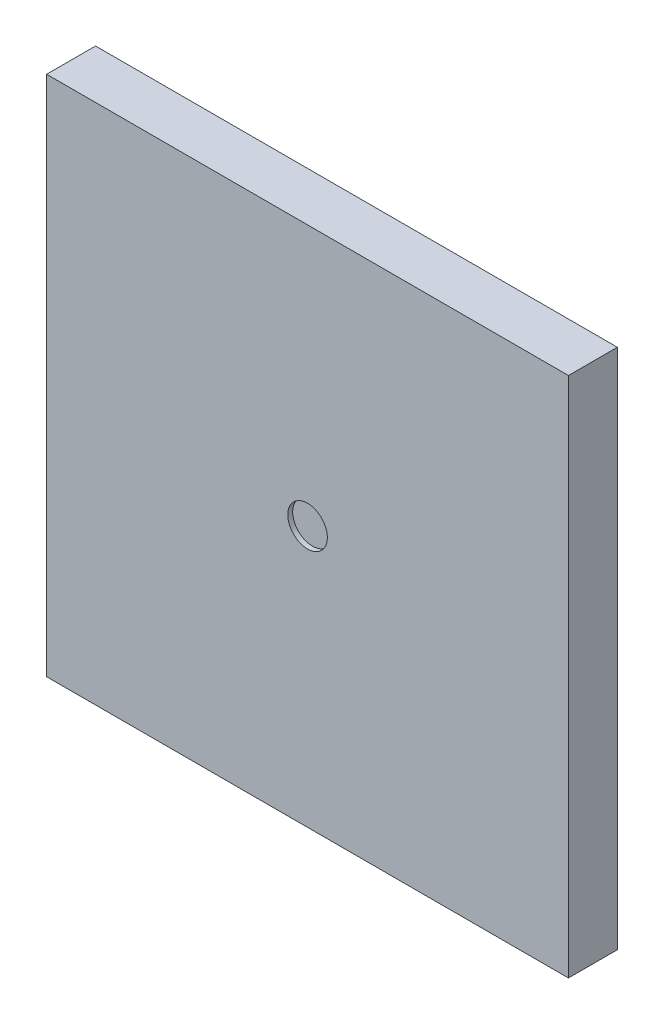
from build123d import *

# Parameters (mm, degrees)
SKETCH1_W          = 27.1
SKETCH1_H          = 27.1
EXTRUDE1_DEPTH     = 2.54
SKETCH2_R          = 1.02820863
CUT_EXTRUDE1_DEPTH = 0.254


with BuildPart() as part:
    # Sketch1 → Extrude1 (new body)
    with BuildSketch(Plane.XY):
        Rectangle(SKETCH1_W, SKETCH1_H)
    extrude(amount=EXTRUDE1_DEPTH)

    # Sketch2 → Cut-Extrude1 (cut)
    with BuildSketch(Plane.XY.offset(2.54)):
        Circle(SKETCH2_R)
    extrude(amount=-CUT_EXTRUDE1_DEPTH, mode=Mode.SUBTRACT)


solid = part.part
